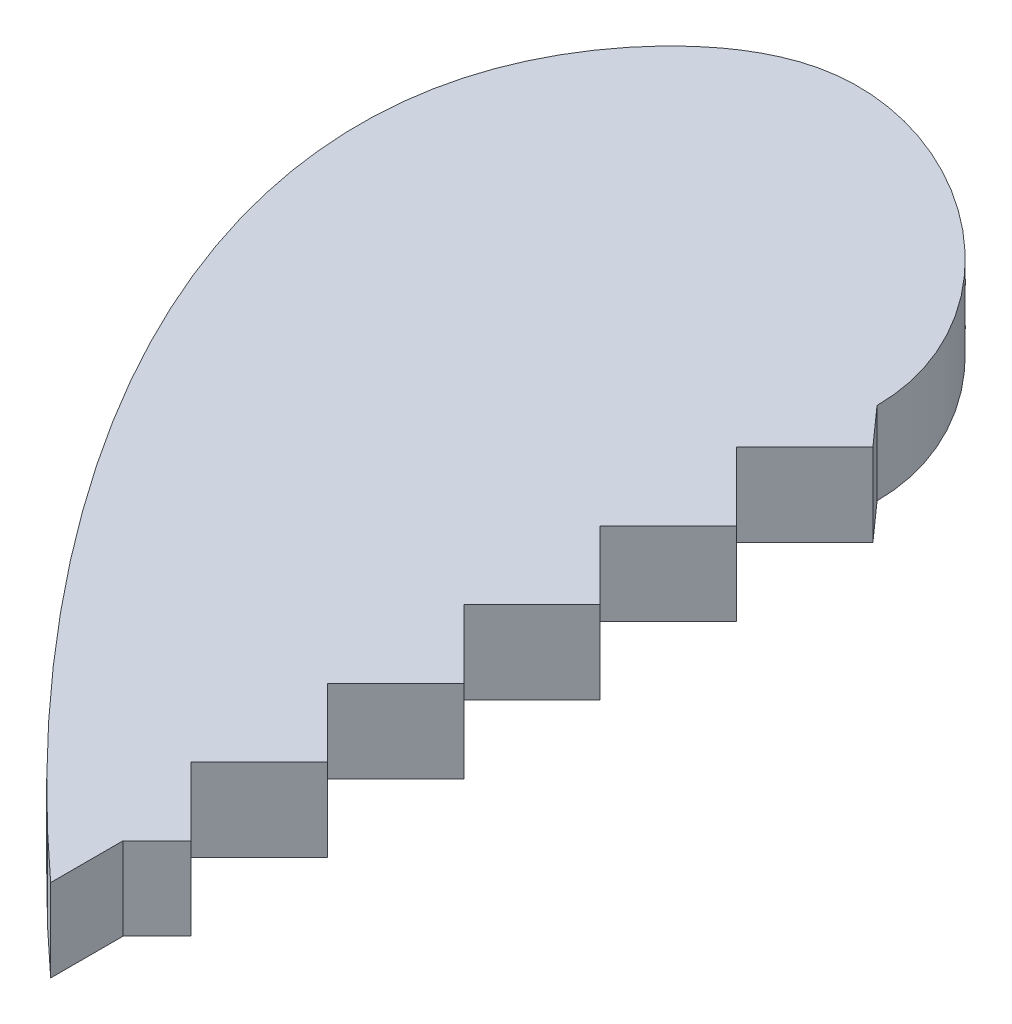
from build123d import *

# Parameters (mm, degrees)
BOSS_EXTRUDE1_DEPTH = 3
CUT_EXTRUDE1_DEPTH  = 3


with BuildPart() as part:
    # Sketch1 → Boss-Extrude1 (new body)
    with BuildSketch(Plane(origin=(0, 0, 0), x_dir=(1, 0, 0), z_dir=(0, 1, 0))):
        with BuildLine():
            add(Edge.make_bspline(
                [(0, 14.072144476), (0, 19.244859197), (9.420520606, 26.756374749), (24.913753139, 13.272155804), (11.532977672, -5.454623459), (0, -15.927855524)],
                knots=[0, 0, 0, 0, 0.261667034, 0.361667034, 1, 1, 1, 1], degree=3))
            add(Edge.make_bspline(
                [(0, 14.072144476), (0, 19.244859197), (-9.420520606, 26.756374749), (-24.913753139, 13.272155804), (-11.532977672, -5.454623459), (0, -15.927855524)],
                knots=[0, 0, 0, 0, 0.261667034, 0.361667034, 1, 1, 1, 1], degree=3))
        make_face()
    extrude(amount=BOSS_EXTRUDE1_DEPTH)

    # Sketch3 → Cut-Extrude1 (cut)
    with BuildSketch(Plane(origin=(0, 3, 0), x_dir=(1, 0, 0), z_dir=(0, 1, 0))):
        with BuildLine():
            Line((0, 14.072144476), (1.237436867, 12.683950014))
            Line((1.237436867, 12.683950014), (-1.237436867, 10.20907628))
            Line((-1.237436867, 10.20907628), (1.237436867, 7.734202545))
            Line((1.237436867, 7.734202545), (-1.237436867, 5.259328811))
            Line((-1.237436867, 5.259328811), (1.237436867, 2.784455077))
            Line((1.237436867, 2.784455077), (-1.237436867, 0.309581343))
            Line((-1.237436867, 0.309581343), (1.237436867, -2.165292391))
            Line((1.237436867, -2.165292391), (-1.237436867, -4.640166125))
            Line((-1.237436867, -4.640166125), (1.237436867, -7.11503986))
            Line((1.237436867, -7.11503986), (-1.237436867, -9.589913594))
            Line((-1.237436867, -9.589913594), (1.237436867, -12.064787328))
            Line((1.237436867, -12.064787328), (0, -13.302224195))
            Line((0, -13.302224195), (0, -15.927855524))
            add(Edge.make_bspline(
                [(0, -15.927855524), (11.532977672, -5.454623459), (24.913753139, 13.272155804), (9.420520606, 26.756374749), (0, 19.244859197), (0, 14.072144476)],
                knots=[0, 0, 0, 0, 0.638332966, 0.738332966, 1, 1, 1, 1], degree=3))
        make_face()
    extrude(amount=-CUT_EXTRUDE1_DEPTH, mode=Mode.SUBTRACT)


solid = part.part
